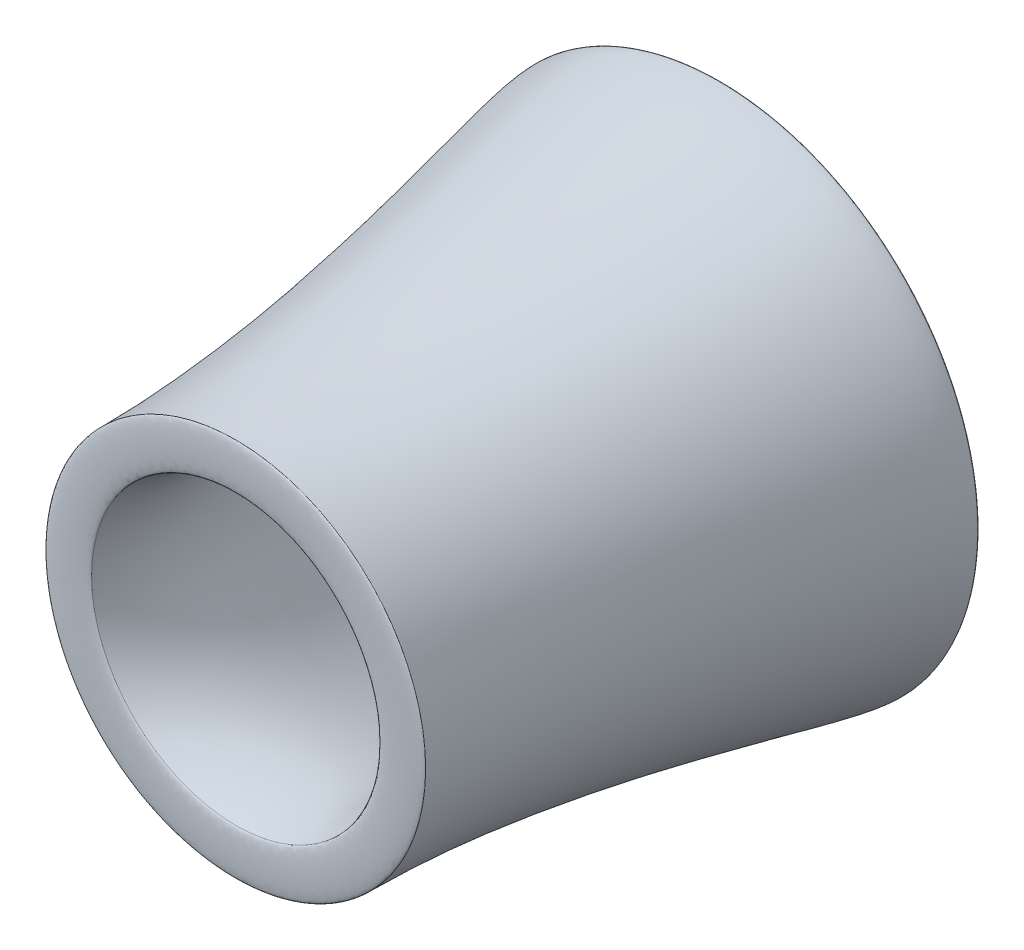
from build123d import *


with BuildPart() as part:
    # Sketch21 → Revolve2 (revolve)
    with BuildSketch(Plane(origin=(0, 0, 0), x_dir=(1, 0, 0), z_dir=(0, 1, 0))):
        with BuildLine():
            Line((-486.277635526, -1251.995775699), (-639.334180406, -1251.995775699))
            add(Edge.make_bspline(
                [(-871.564148405, 376.226327562), (-871.564148405, 250.842375186), (-639.334180406, -521.686655314), (-639.334180406, -1251.995775699)],
                knots=[0, 0, 0, 0, 1, 1, 1, 1], degree=3))
            Line((-871.564148405, 376.226327562), (-710.453833657, 376.226327562))
            add(Edge.make_bspline(
                [(-710.453833657, 376.226327562), (-720.021859821, 125.212813059), (-670.556964644, -438.724566684), (-344.132485944, -890.184387248), (-486.277635526, -1251.995775699)],
                knots=[0, 0, 0, 0, 0.206506907, 1, 1, 1, 1], degree=3))
        make_face()
    revolve(axis=Axis((0, 0, 99.684784321), (0, 0, -1)))


with BuildPart() as body_2:
    # Sketch22 → Revolve3 (revolve)
    with BuildSketch(Plane(origin=(0, 0, 0), x_dir=(1, 0, 0), z_dir=(0, 1, 0))):
        with BuildLine():
            Line((-871.564148405, 376.226327562), (-710.453833657, 376.226327562))
            add(Edge.make_bspline(
                [(-871.564148405, 376.226327562), (-871.564148405, 393.159660896), (-710.453833657, 393.159660896), (-710.453833657, 376.226327562)],
                knots=[0, 0, 0, 0, 1, 1, 1, 1], degree=3))
        make_face()
    revolve(axis=Axis((0, 0, 99.684784321), (0, 0, -1)))


with BuildPart() as body_3:
    # Sketch23 → Revolve4 (revolve)
    with BuildSketch(Plane(origin=(0, 0, 0), x_dir=(1, 0, 0), z_dir=(0, 1, 0))):
        with BuildLine():
            Line((-639.334180406, -1251.995775699), (-486.277635526, -1251.995775699))
            add(Edge.make_bspline(
                [(-639.334180406, -1251.995775699), (-639.334180406, -1264.695775699), (-486.277635526, -1264.695775699), (-486.277635526, -1251.995775699)],
                knots=[0, 0, 0, 0, 1, 1, 1, 1], degree=3))
        make_face()
    revolve(axis=Axis((0, 0, 1104.756830123), (0, 0, -1)))


solid = Compound([part.part, body_2.part, body_3.part])
